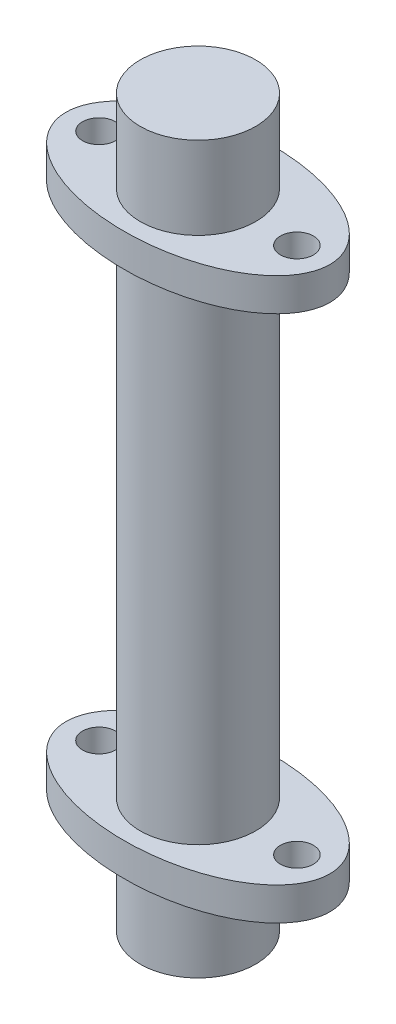
from build123d import *

# Parameters (mm, degrees)
ESQUISSE1_R        = 3.5
BOSS_EXTRU_1_DEPTH = 15
ESQUISSE2_RX       = 8
ESQUISSE2_RY       = 4.5
ESQUISSE2_R        = 1
BOSS_EXTRU_2_DEPTH = 2
ESQUISSE4_R        = 3.5
BOSS_EXTRU_3_DEPTH = 5


with BuildPart() as part:
    # Esquisse1 → Boss.-Extru.1 (new body)
    with BuildSketch(Plane(origin=(0, 0, 0), x_dir=(1, 0, 0), z_dir=(0, 1, 0))):
        Circle(ESQUISSE1_R)
    boss_extru_1 = extrude(amount=BOSS_EXTRU_1_DEPTH)

    # Esquisse2 → Boss.-Extru.2 (add)
    with BuildSketch(Plane(origin=(0, 15, 0), x_dir=(1, 0, 0), z_dir=(0, 1, 0))):
        with Locations((0, 0)):
            Ellipse(ESQUISSE2_RX, ESQUISSE2_RY)
        with Locations((6, 0)):
            Circle(ESQUISSE2_R, mode=Mode.SUBTRACT)
        with Locations((-6, 0)):
            Circle(ESQUISSE2_R, mode=Mode.SUBTRACT)
    boss_extru_2 = extrude(amount=BOSS_EXTRU_2_DEPTH)

    # Esquisse4 → Boss.-Extru.3 (add)
    with BuildSketch(Plane(origin=(0, 17, 0), x_dir=(1, 0, 0), z_dir=(0, 1, 0))):
        Circle(ESQUISSE4_R)
    boss_extru_3 = extrude(amount=BOSS_EXTRU_3_DEPTH)

    # Symétrie1: Boss.-Extru.1, Boss.-Extru.2, Boss.-Extru.3 across plane
    add(boss_extru_1.mirror(Plane.ZX))
    add(boss_extru_2.mirror(Plane.ZX))
    add(boss_extru_3.mirror(Plane.ZX))


solid = part.part
